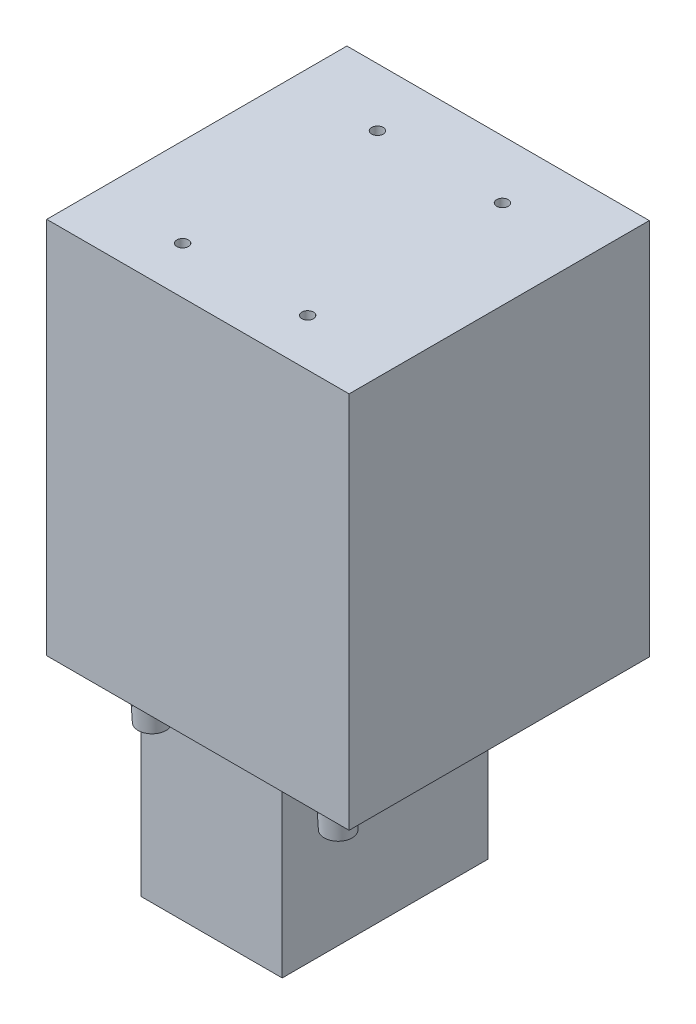
from build123d import *

# Parameters (mm, degrees)
SKETCH1_W           = 24.25
SKETCH1_H           = 35.375
SKETCH1_R           = 1
SKETCH1_W_2         = 16.25
SKETCH1_W_3         = 11.5
SKETCH1_R_2         = 2.875
BOSS_EXTRUDE1_DEPTH = 65
CUT_EXTRUDE1_START  = 65
SKETCH1_3_R         = 1
CUT_EXTRUDE1_DEPTH  = 15
SKETCH1_4_W         = 24.25
SKETCH1_4_H         = 35.375
SKETCH1_4_R         = 1
BOSS_EXTRUDE2_DEPTH = 44
SKETCH1_5_R         = 2.875
BOSS_EXTRUDE3_DEPTH = 9
BOSS_EXTRUDE3_TAPER = 3


with BuildPart() as part:
    # Sketch1 → Boss-Extrude1 (new body)
    with BuildSketch(Plane(origin=(0, 0, 0), x_dir=(1, 0, 0), z_dir=(0, 1, 0))):
        with Locations((-28.375, 17.6875)):
            Rectangle(SKETCH1_W, SKETCH1_H)
        with Locations((-25.25, 25.375)):
            Circle(SKETCH1_R, mode=Mode.SUBTRACT)
        with Locations((-8.125, 17.6875)):
            Rectangle(SKETCH1_W_2, SKETCH1_H)
        with Locations((-3.75, 25.375)):
            Circle(SKETCH1_R, mode=Mode.SUBTRACT)
        with Locations((5.75, 17.6875)):
            Rectangle(SKETCH1_W_3, SKETCH1_H)
        Polygon((11.5, 0), (0, 0), (-16.25, 0), (-40.5, 0), (-40.5, -16.25), (11.5, -16.25), align=None)
        with Locations((-30.5, -8.125)):
            Circle(SKETCH1_R_2, mode=Mode.SUBTRACT)
        with Locations((-25.25, -8.125)):
            Circle(SKETCH1_R, mode=Mode.SUBTRACT)
        with Locations((-3.75, -8.125)):
            Circle(SKETCH1_R, mode=Mode.SUBTRACT)
        with Locations((1.5, -8.125)):
            Circle(SKETCH1_R_2, mode=Mode.SUBTRACT)
        with Locations((-30.5, -8.125)):
            Circle(SKETCH1_R_2)
        with Locations((1.5, -8.125)):
            Circle(SKETCH1_R_2)
        with Locations((-3.75, -8.125)):
            Circle(SKETCH1_R)
        with Locations((-3.75, 25.375)):
            Circle(SKETCH1_R)
        with Locations((-25.25, 25.375)):
            Circle(SKETCH1_R)
        with Locations((-25.25, -8.125)):
            Circle(SKETCH1_R)
    extrude(amount=BOSS_EXTRUDE1_DEPTH)

    # Sketch1_3 → Cut-Extrude1 (cut)
    with BuildSketch(Plane(origin=(0, 0, 0), x_dir=(1, 0, 0), z_dir=(0, 1, 0)).offset(CUT_EXTRUDE1_START)):
        with Locations((-3.75, -8.125)):
            Circle(SKETCH1_3_R)
        with Locations((-25.25, -8.125)):
            Circle(SKETCH1_3_R)
        with Locations((-3.75, 25.375)):
            Circle(SKETCH1_3_R)
        with Locations((-25.25, 25.375)):
            Circle(SKETCH1_3_R)
    extrude(amount=-CUT_EXTRUDE1_DEPTH, mode=Mode.SUBTRACT)

    # Sketch1_4 → Boss-Extrude2 (add)
    with BuildSketch(Plane(origin=(0, 0, 0), x_dir=(1, 0, 0), z_dir=(0, 1, 0))):
        with Locations((-28.375, 17.6875)):
            Rectangle(SKETCH1_4_W, SKETCH1_4_H)
        with Locations((-25.25, 25.375)):
            Circle(SKETCH1_4_R, mode=Mode.SUBTRACT)
        with Locations((-25.25, 25.375)):
            Circle(SKETCH1_4_R)
    extrude(amount=-BOSS_EXTRUDE2_DEPTH)

    # Sketch1_5 → Boss-Extrude3 (add)
    with BuildSketch(Plane(origin=(0, 0, 0), x_dir=(1, 0, 0), z_dir=(0, 1, 0))):
        with Locations((1.5, -8.125)):
            Circle(SKETCH1_5_R)
        with Locations((-30.5, -8.125)):
            Circle(SKETCH1_5_R)
    extrude(amount=-BOSS_EXTRUDE3_DEPTH, taper=BOSS_EXTRUDE3_TAPER)


solid = part.part
